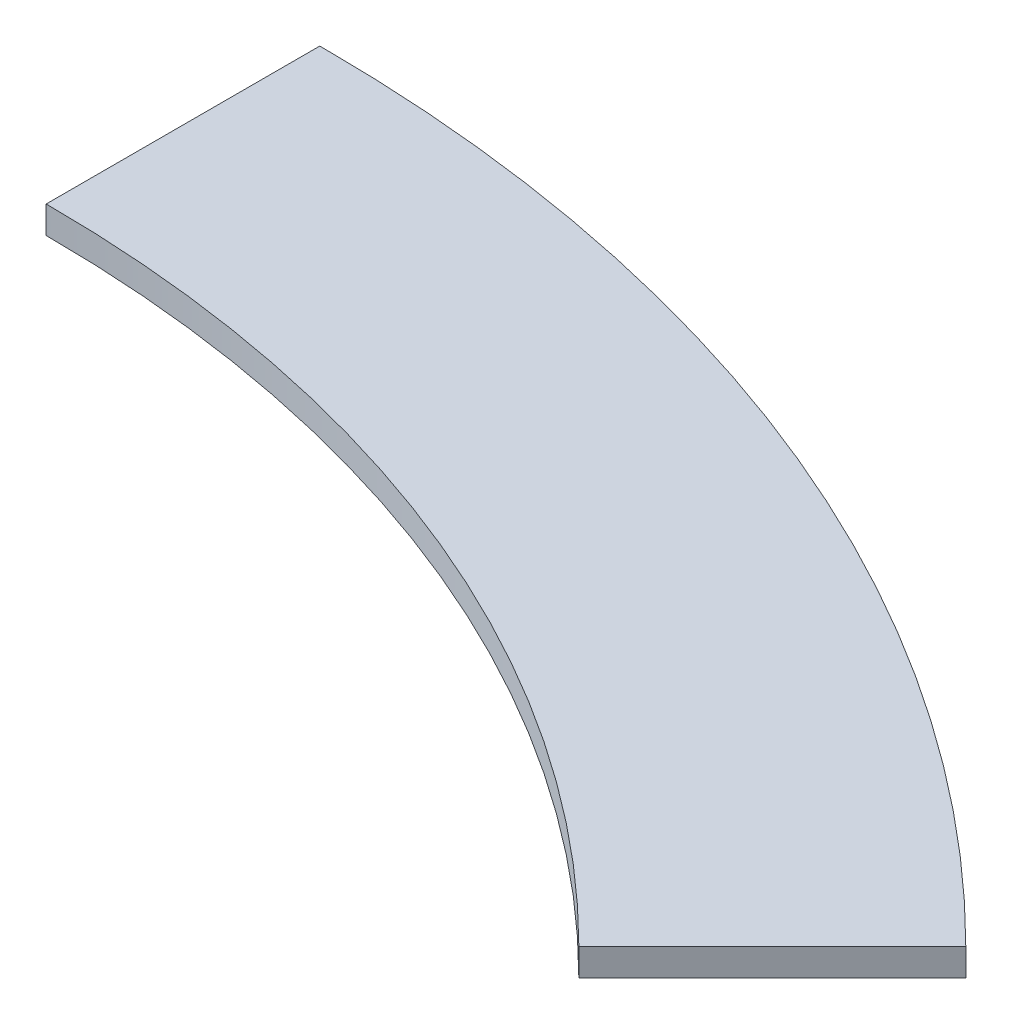
from build123d import *

# Parameters (mm, degrees)
BOSS_EXTRUDE1_DEPTH = 10


with BuildPart() as part:
    # Sketch1 → Boss-Extrude1 (new body)
    with BuildSketch(Plane(origin=(0, 0, 0), x_dir=(1, 0, 0), z_dir=(0, 1, 0))):
        with BuildLine():
            ThreePointArc((0, 570), (218.129556448, 526.611333531), (403.050865276, 403.050865276))
            Line((403.050865276, 403.050865276), (332.340187158, 332.340187158))
            ThreePointArc((332.340187158, 332.340187158), (179.861213212, 434.22338028), (0, 470))
            Line((0, 470), (0, 570))
        make_face()
    extrude(amount=BOSS_EXTRUDE1_DEPTH)


solid = part.part
